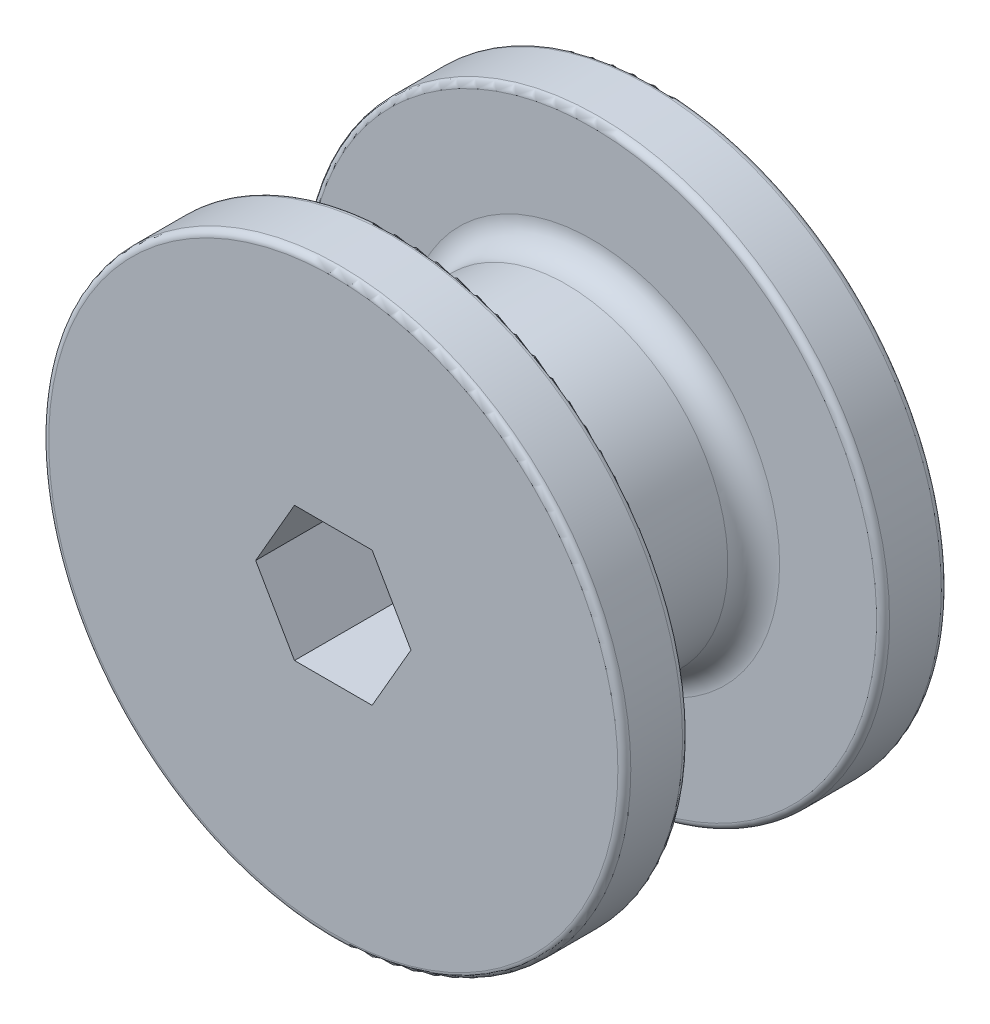
from build123d import *

# Parameters (mm, degrees)
SKETCH1_R           = 15.875
BOSS_EXTRUDE1_DEPTH = 19.05
SKETCH2_R           = 28.575
BOSS_EXTRUDE2_DEPTH = 6.35
SKETCH3_R           = 28.575
BOSS_EXTRUDE3_DEPTH = 6.35
CUT_EXTRUDE1_DEPTH  = 32.75
FILLET1_R           = 2.54
FILLET2_R           = 0.635


with BuildPart() as part:
    # Sketch1 → Boss-Extrude1 (new body)
    with BuildSketch(Plane.XY):
        Circle(SKETCH1_R)
    extrude(amount=BOSS_EXTRUDE1_DEPTH)

    # Sketch2 → Boss-Extrude2 (add)
    with BuildSketch(Plane.XY.offset(19.05)):
        Circle(SKETCH2_R)
    extrude(amount=BOSS_EXTRUDE2_DEPTH)

    # Sketch3 → Boss-Extrude3 (add)
    with BuildSketch(Plane(origin=(0, 0, 0), x_dir=(-1, 0, 0), z_dir=(0, 0, -1))):
        Circle(SKETCH3_R)
    extrude(amount=BOSS_EXTRUDE3_DEPTH)

    # Sketch4 → Cut-Extrude1 (cut, through all)
    with BuildSketch(Plane(origin=(0, 0, -6.35), x_dir=(-1, 0, 0), z_dir=(0, 0, -1))):
        Polygon((7.621023553, 0), (3.810511777, 6.6), (-3.810511777, 6.6), (-7.621023553, 0), (-3.810511777, -6.6), (3.810511777, -6.6), align=None)
    extrude(amount=-CUT_EXTRUDE1_DEPTH, mode=Mode.SUBTRACT)

    # Fillet1
    fillet1_edges = [part.edges().sort_by_distance(p)[0] for p in [
        (-15.875, 0, 19.05),
        (-15.875, 0, 0),
    ]]
    fillet(fillet1_edges, radius=FILLET1_R)

    # Fillet2
    fillet2_edges = [part.edges().sort_by_distance(p)[0] for p in [
        (28.575, 0, -6.35),
        (-28.575, 0, 19.05),
        (-28.575, 0, 25.4),
        (28.575, 0, 0),
    ]]
    fillet(fillet2_edges, radius=FILLET2_R)


solid = part.part
